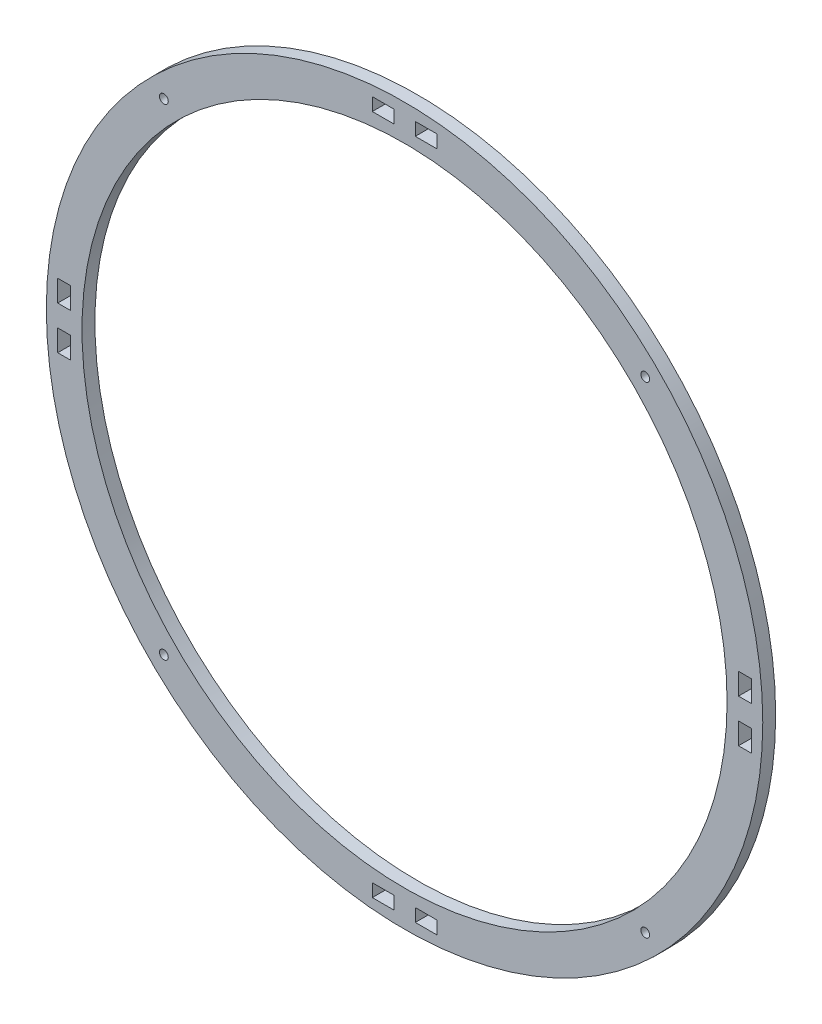
from build123d import *

# Parameters (mm, degrees)
SALIENTE_EXTRUIR1_DEPTH = 6
CROQUIS2_W              = 10
CROQUIS2_H              = 6
CROQUIS2_W_2            = 6
CROQUIS2_H_2            = 10
CORTAR_EXTRUIR1_DEPTH   = 10


with BuildPart() as part:
    # Croquis1 → Saliente-Extruir1 (new body)
    with BuildSketch(Plane.XY):
        with BuildLine():
            ThreePointArc((40.600971411, -36.999917491), (17.069259083, -64.251458669), (-0.057755376, -95.922476295))
            ThreePointArc((-0.057755376, -95.922476295), (122.116838757, -322.352188967), (320.78926855, -158.870349387))
            ThreePointArc((320.78926855, -158.870349387), (317.672636714, -126.79639101), (308.439349644, -95.922476295))
            ThreePointArc((308.439349644, -95.922476295), (291.312335185, -64.251458669), (267.780622857, -36.999917491))
            ThreePointArc((267.780622857, -36.999917491), (154.190797134, 7.728122029), (40.600971411, -36.999917491))
        make_face()
        with BuildLine():
            ThreePointArc((50.939396199, -50.062499464), (51.321581101, -49.701102835), (51.705030941, -49.341048614))
            ThreePointArc((51.705030941, -49.341048614), (213.886421224, -21.26063874), (304.190797134, -158.870349387))
            ThreePointArc((304.190797134, -158.870349387), (94.978087942, -296.688545102), (50.939396199, -50.062499464))
        make_face(mode=Mode.SUBTRACT)
    extrude(amount=SALIENTE_EXTRUIR1_DEPTH)

    # Croquis2 → Cortar-Extruir1 (cut)
    with BuildSketch(Plane.XY.offset(6)):
        Polygon((139.190797134, -3.571113679), (149.190797134, -3.571113679), (149.190797134, -0.571113679), (149.190797134, 2.428886321), (139.190797134, 2.428886321), align=None)
        with Locations((164.190797134, -0.571113679)):
            Rectangle(CROQUIS2_W, CROQUIS2_H)
        with Locations((312.490032842, -148.870349387)):
            Rectangle(CROQUIS2_W_2, CROQUIS2_H_2)
        Polygon((312.490032842, -163.870349387), (315.490032842, -163.870349387), (315.490032842, -173.870349387), (309.490032842, -173.870349387), (309.490032842, -163.870349387), align=None)
        with Locations((164.190797134, -317.169585095)):
            Rectangle(CROQUIS2_W, CROQUIS2_H)
        Polygon((149.190797134, -317.169585095), (149.190797134, -314.169585095), (139.190797134, -314.169585095), (139.190797134, -320.169585095), (149.190797134, -320.169585095), align=None)
        with Locations((-4.108438574, -148.870349387)):
            Rectangle(CROQUIS2_W_2, CROQUIS2_H_2)
        Polygon((-7.108438574, -173.870349387), (-7.108438574, -163.870349387), (-4.108438574, -163.870349387), (-1.108438574, -163.870349387), (-1.108438574, -173.870349387), align=None)
        with BuildLine():
            ThreePointArc((40.806765207, -45.48631746), (40.806765207, -48.385455263), (43.705903009, -48.385455263))
            Line((43.705903009, -48.385455263), (40.806765207, -45.48631746))
        make_face()
        with BuildLine():
            Line((40.806765207, -45.48631746), (43.705903009, -48.385455263))
            ThreePointArc((43.705903009, -48.385455263), (44.15028715, -47.720387398), (44.306334108, -46.935886361))
            ThreePointArc((44.306334108, -46.935886361), (43.040835144, -45.04193332), (40.806765207, -45.48631746))
        make_face()
        with BuildLine():
            ThreePointArc((267.574829061, -45.48631746), (264.675691258, -45.48631746), (264.675691258, -48.385455263))
            Line((264.675691258, -48.385455263), (267.574829061, -45.48631746))
        make_face()
        with BuildLine():
            Line((267.574829061, -45.48631746), (264.675691258, -48.385455263))
            ThreePointArc((264.675691258, -48.385455263), (266.909761196, -48.829839403), (268.17526016, -46.935886361))
            ThreePointArc((268.17526016, -46.935886361), (268.019213202, -46.151385325), (267.574829061, -45.48631746))
        make_face()
        with BuildLine():
            ThreePointArc((268.17526016, -270.804812413), (266.909761196, -268.910859371), (264.675691258, -269.355243512))
            Line((264.675691258, -269.355243512), (267.574829061, -272.254381314))
            ThreePointArc((267.574829061, -272.254381314), (268.019213202, -271.589313449), (268.17526016, -270.804812413))
        make_face()
        with BuildLine():
            Line((267.574829061, -272.254381314), (264.675691258, -269.355243512))
            ThreePointArc((264.675691258, -269.355243512), (264.675691258, -272.254381314), (267.574829061, -272.254381314))
        make_face()
        with BuildLine():
            ThreePointArc((44.306334108, -270.804812413), (44.15028715, -270.020311377), (43.705903009, -269.355243512))
            Line((43.705903009, -269.355243512), (40.806765207, -272.254381314))
            ThreePointArc((40.806765207, -272.254381314), (43.040835144, -272.698765455), (44.306334108, -270.804812413))
        make_face()
        with BuildLine():
            Line((40.806765207, -272.254381314), (43.705903009, -269.355243512))
            ThreePointArc((43.705903009, -269.355243512), (40.806765207, -269.355243512), (40.806765207, -272.254381314))
        make_face()
    extrude(amount=-CORTAR_EXTRUIR1_DEPTH, mode=Mode.SUBTRACT)


solid = part.part
